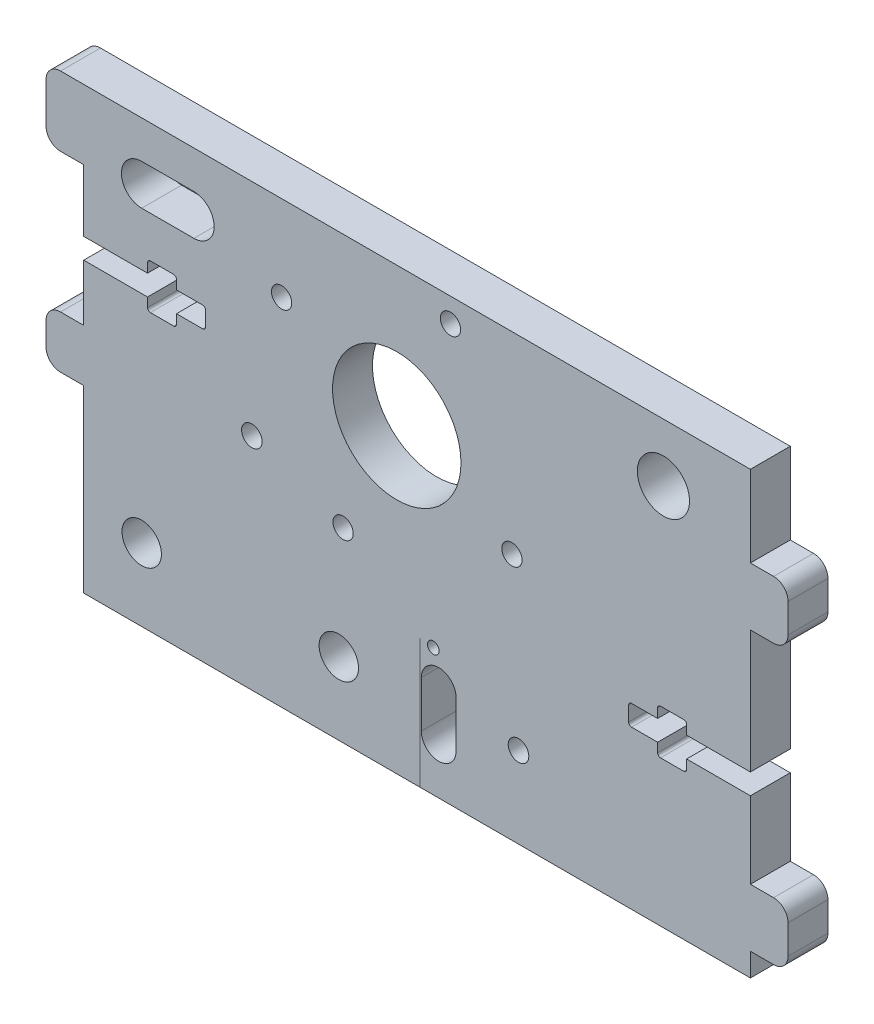
from build123d import *

# Parameters (mm, degrees)
SKETCH1_W           = 115
SKETCH1_H           = 76
SKETCH1_R           = 1.75
SKETCH1_R_2         = 11.075
BOSS_EXTRUDE1_DEPTH = 6.88
SKETCH2_R           = 3.4
CUT_EXTRUDE1_DEPTH  = 7.88
SKETCH4_R           = 1.775
CUT_EXTRUDE3_DEPTH  = 7.88
SKETCH6_W           = 13
SKETCH6_H           = 10
SKETCH6_W_2         = 19
BOSS_EXTRUDE2_DEPTH = 6.88
SKETCH7_W           = 42
SKETCH7_H           = 3.55
CUT_EXTRUDE4_DEPTH  = 7.88
SKETCH8_W           = 5
SKETCH8_H           = 7.72
CUT_EXTRUDE5_DEPTH  = 7.88
SKETCH9_W           = 0.137025634
SKETCH9_H           = 44.465022332
CUT_EXTRUDE6_DEPTH  = 0.005
SKETCH10_W          = 42
SKETCH10_H          = 3.55
CUT_EXTRUDE7_DEPTH  = 7.88
SKETCH11_W          = 5
SKETCH11_H          = 7.72
CUT_EXTRUDE8_DEPTH  = 7.88
FILLET1_R           = 0.5
CUT_EXTRUDE10_DEPTH = 7.88
SKETCH14_W          = 6.5
SKETCH14_H          = 12
SKETCH14_H_2        = 9
BOSS_EXTRUDE3_DEPTH = 6.88
SKETCH15_R          = 4.5
CUT_EXTRUDE11_DEPTH = 7.88
FILLET2_R           = 2.5
SKETCH17_R          = 1
CUT_EXTRUDE12_DEPTH = 7.88


with BuildPart() as part:
    # Sketch1 → Boss-Extrude1 (new body)
    with BuildSketch(Plane.XY):
        Rectangle(SKETCH1_W, SKETCH1_H)
        with Locations((-23.366547844, 23.263923401)):
            Circle(SKETCH1_R, mode=Mode.SUBTRACT)
        with Locations((-3.5, 14)):
            Circle(SKETCH1_R_2, mode=Mode.SUBTRACT)
        with Locations((5.763923401, 33.866547844)):
            Circle(SKETCH1_R, mode=Mode.SUBTRACT)
        with Locations((16.366547844, 4.736076599)):
            Circle(SKETCH1_R, mode=Mode.SUBTRACT)
        with Locations((-12.763923401, -5.866547844)):
            Circle(SKETCH1_R, mode=Mode.SUBTRACT)
    extrude(amount=BOSS_EXTRUDE1_DEPTH)

    # Sketch2 → Cut-Extrude1 (cut, through all)
    with BuildSketch(Plane.XY.offset(6.88)):
        with Locations((-47.5, -25.5)):
            Circle(SKETCH2_R)
        with Locations((-13.5, -25.5)):
            Circle(SKETCH2_R)
    extrude(amount=-CUT_EXTRUDE1_DEPTH, mode=Mode.SUBTRACT)

    # Sketch4 → Cut-Extrude3 (cut, through all)
    with BuildSketch(Plane.XY.offset(6.88)):
        with Locations((17.5, -24)):
            Circle(SKETCH4_R)
        with Locations((-28.5, 0)):
            Circle(SKETCH4_R)
    extrude(amount=-CUT_EXTRUDE3_DEPTH, mode=Mode.SUBTRACT)

    # Sketch6 → Boss-Extrude2 (add)
    with BuildSketch(Plane.XY.offset(6.88)):
        with Locations((57.5, 19)):
            Rectangle(SKETCH6_W, SKETCH6_H)
        with Locations((54.5, -29)):
            Rectangle(SKETCH6_W_2, SKETCH6_H)
    extrude(amount=-BOSS_EXTRUDE2_DEPTH)

    # Sketch7 → Cut-Extrude4 (cut, through all)
    with BuildSketch(Plane.XY.offset(6.88)):
        with Locations((57.5, -9)):
            Rectangle(SKETCH7_W, SKETCH7_H)
    extrude(amount=-CUT_EXTRUDE4_DEPTH, mode=Mode.SUBTRACT)

    # Sketch8 → Cut-Extrude5 (cut, through all)
    with BuildSketch(Plane.XY.offset(6.88)):
        with Locations((44, -9)):
            Rectangle(SKETCH8_W, SKETCH8_H)
    extrude(amount=-CUT_EXTRUDE5_DEPTH, mode=Mode.SUBTRACT)

    # Sketch9 → Cut-Extrude6 (cut)
    with BuildSketch(Plane.XY.offset(6.88)):
        with Locations((0.5, -38)):
            Rectangle(SKETCH9_W, SKETCH9_H)
    extrude(amount=-CUT_EXTRUDE6_DEPTH, mode=Mode.SUBTRACT)

    # Sketch10 → Cut-Extrude7 (cut, through all)
    with BuildSketch(Plane.XY.offset(6.88)):
        with Locations((-57.5, 13.517811254)):
            Rectangle(SKETCH10_W, SKETCH10_H)
    extrude(amount=-CUT_EXTRUDE7_DEPTH, mode=Mode.SUBTRACT)

    # Sketch11 → Cut-Extrude8 (cut, through all)
    with BuildSketch(Plane.XY.offset(6.88)):
        with Locations((-44, 13.517811254)):
            Rectangle(SKETCH11_W, SKETCH11_H)
    extrude(amount=-CUT_EXTRUDE8_DEPTH, mode=Mode.SUBTRACT)

    # Fillet1
    fillet1_edges = [part.edges().sort_by_distance(p)[0] for p in [
        (36.5, -7.225, 3.44),
        (36.5, -10.775, 3.44),
        (46.5, -5.14, 3.44),
        (41.5, -12.86, 3.44),
        (46.5, -12.86, 3.44),
        (41.5, -5.14, 3.44),
        (-36.5, 11.742811254, 3.44),
        (-36.5, 15.292811254, 3.44),
        (-41.5, 17.377811254, 3.44),
        (-46.5, 9.657811254, 3.44),
        (-41.5, 9.657811254, 3.44),
        (-46.5, 17.377811254, 3.44),
    ]]
    fillet(fillet1_edges, radius=FILLET1_R)

    # Sketch13 → Cut-Extrude10 (cut, through all)
    with BuildSketch(Plane.XY.offset(6.88)):
        with BuildLine():
            Line((6.731487183, -21.5), (6.731487183, -29.5))
            ThreePointArc((6.731487183, -29.5), (3.731487183, -32.5), (0.731487183, -29.5))
            Line((0.731487183, -29.5), (0.731487183, -21.5))
            ThreePointArc((0.731487183, -21.5), (3.731487183, -18.5), (6.731487183, -21.5))
        make_face()
    extrude(amount=-CUT_EXTRUDE10_DEPTH, mode=Mode.SUBTRACT)

    # Sketch14 → Boss-Extrude3 (add)
    with BuildSketch(Plane.XY.offset(6.88)):
        with Locations((-60.75, 32)):
            Rectangle(SKETCH14_W, SKETCH14_H)
        with Locations((-60.75, -2.5)):
            Rectangle(SKETCH14_W, SKETCH14_H_2)
    extrude(amount=-BOSS_EXTRUDE3_DEPTH)

    # Sketch15 → Cut-Extrude11 (cut, through all)
    with BuildSketch(Plane.XY.offset(6.88)):
        with Locations((42.5, 28)):
            Circle(SKETCH15_R)
        with BuildLine():
            Line((-47.5, 31.5), (-38.5, 31.5))
            ThreePointArc((-38.5, 31.5), (-35, 28), (-38.5, 24.5))
            Line((-38.5, 24.5), (-47.5, 24.5))
            ThreePointArc((-47.5, 24.5), (-51, 28), (-47.5, 31.5))
        make_face()
    extrude(amount=-CUT_EXTRUDE11_DEPTH, mode=Mode.SUBTRACT)

    # Fillet2
    fillet2_edges = [part.edges().sort_by_distance(p)[0] for p in [
        (-64, 38, 3.44),
        (-64, 26, 3.44),
        (-64, 2, 3.44),
        (-64, -7, 3.44),
        (64, 14, 3.44),
        (64, 24, 3.44),
        (64, -34, 3.44),
        (64, -24, 3.44),
    ]]
    fillet(fillet2_edges, radius=FILLET2_R)

    # Sketch17 → Cut-Extrude12 (cut, through all)
    with BuildSketch(Plane.XY.offset(6.88)):
        with Locations((2.805812791, -16)):
            Circle(SKETCH17_R)
    extrude(amount=-CUT_EXTRUDE12_DEPTH, mode=Mode.SUBTRACT)


solid = part.part
